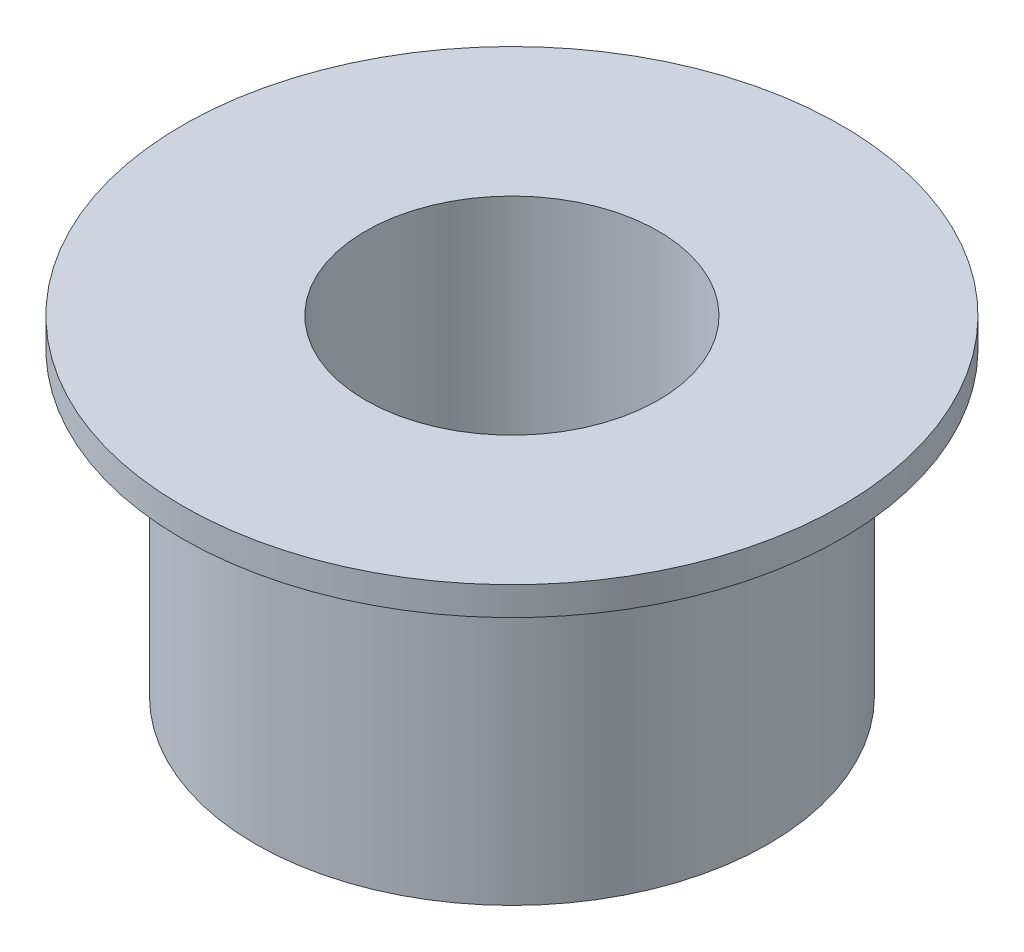
from build123d import *


with BuildPart() as part:
    # Sketch1 → Revolve1 (revolve)
    with BuildSketch(Plane(origin=(0, 0, 0), x_dir=(0, 0, -1), z_dir=(1, 0, 0))):
        Polygon((7, -4.5), (4, -2.5), (4, 4.5), (9, 4.5), (9, 3.721715759), (7, 3.721715759), align=None)
    revolve(axis=Axis((0, 4.5, 0), (0, -1, 0)))


solid = part.part
